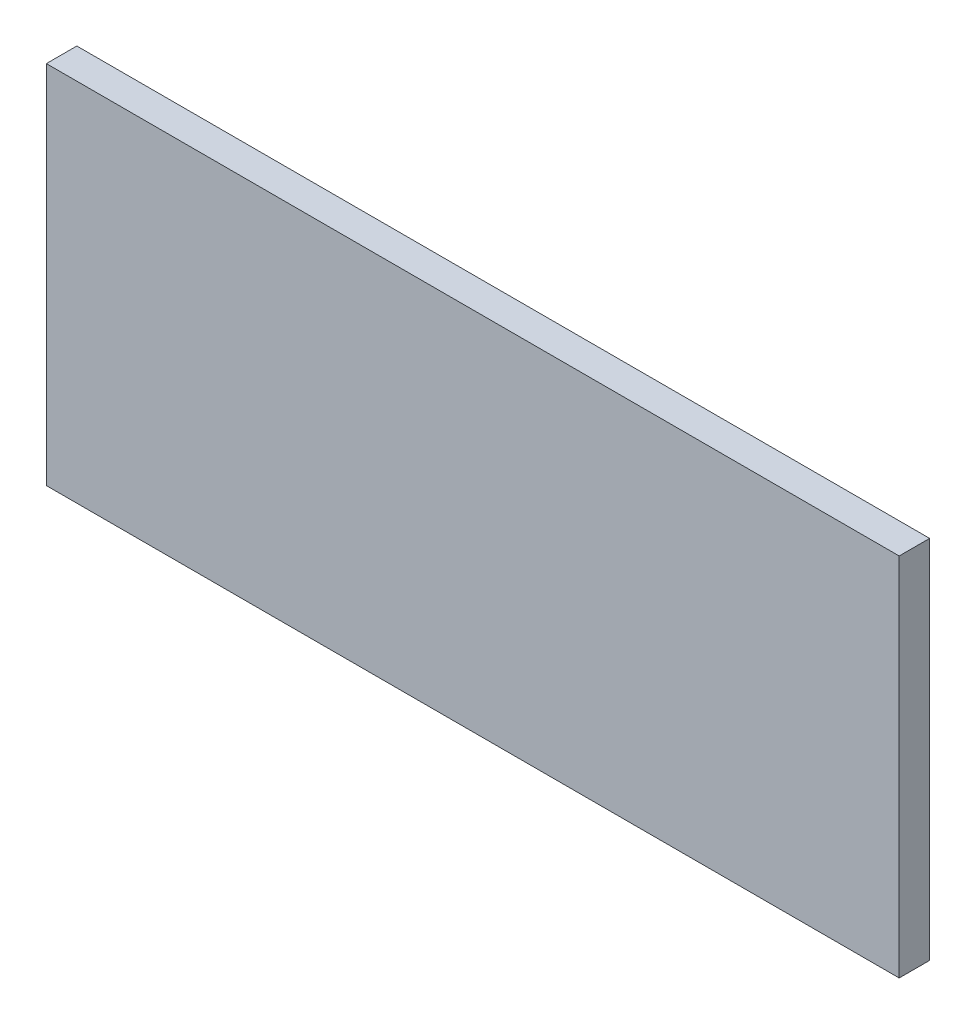
from build123d import *

# Parameters (mm, degrees)
SKETCH1_W           = 177.8
SKETCH1_H           = 76.2
BOSS_EXTRUDE1_DEPTH = 6.35


with BuildPart() as part:
    # Sketch1 → Boss-Extrude1 (new body)
    with BuildSketch(Plane.XY):
        with Locations((88.9, 38.1)):
            Rectangle(SKETCH1_W, SKETCH1_H)
    extrude(amount=BOSS_EXTRUDE1_DEPTH)


solid = part.part
